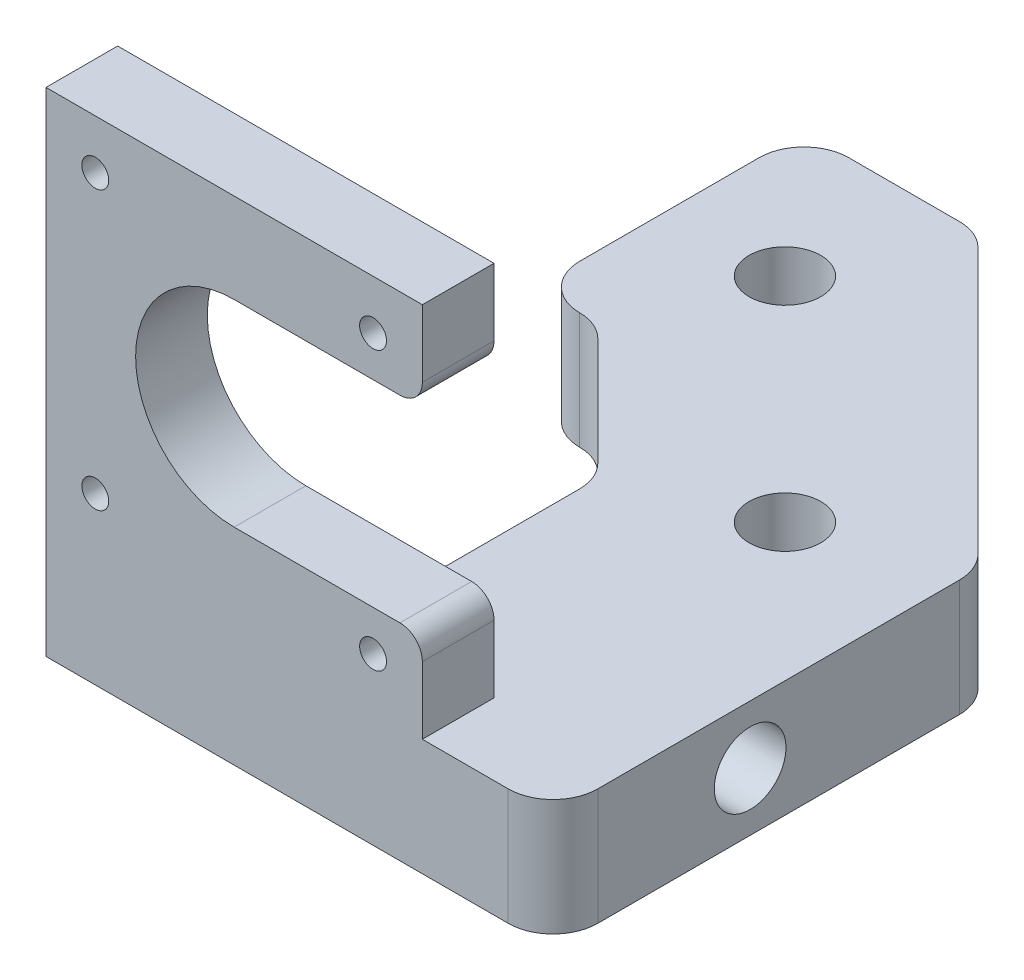
from build123d import *

# Parameters (mm, degrees)
SKETCH1_R       = 4
EXTRUDE1_DEPTH  = 13
FILLET5_R       = 5
FILLET6_R       = 5
SKETCH8_R       = 4
EXTRUDE7_DEPTH  = 30
SKETCH9_W       = 42
SKETCH9_H       = 8
EXTRUDE8_DEPTH  = 42
EXTRUDE9_REACH  = 82
SKETCH10_R      = 11
SKETCH10_R_2    = 1.5
EXTRUDE10_REACH = 10
SKETCH11_W      = 21
SKETCH11_H      = 22
FILLET7_R       = 2.5


with BuildPart() as part:
    # Sketch1 → Extrude1 (new body)
    with BuildSketch(Plane(origin=(0, 0, 0), x_dir=(1, 0, 0), z_dir=(0, 1, 0))):
        Polygon((-26.25, -50), (30.331151632, -50), (30.331151632, -2.573593129), (-2.242441497, 30), (-21.668848368, 30), (-21.668848368, 0), (-14.668848368, 0), (0.331151632, -15), (0.331151632, -42), (-26.25, -42), align=None)
        with Locations((-8.786796564, 15)):
            Circle(SKETCH1_R, mode=Mode.SUBTRACT)
        with Locations((15, -8.786796564)):
            Circle(SKETCH1_R, mode=Mode.SUBTRACT)
    extrude(amount=EXTRUDE1_DEPTH)

    # Fillet5
    fillet5_edges = [part.edges().sort_by_distance(p)[0] for p in [
        (-2.242441497, 6.5, -30),
        (30.331151632, 6.5, 2.573593129),
        (30.331151632, 6.5, 50),
        (0.331151632, 6.5, 15),
        (-14.668848368, 6.5, 0),
    ]]
    fillet(fillet5_edges, radius=FILLET5_R)

    # Fillet6
    fillet6_edges = [part.edges().sort_by_distance(p)[0] for p in [
        (-21.668848368, 6.5, 0),
        (-21.668848368, 6.5, -30),
    ]]
    fillet(fillet6_edges, radius=FILLET6_R)

    # Sketch8 → Extrude7 (cut)
    with BuildSketch(Plane.ZY.offset(-0.331151632)):
        with Locations((28, 6.5)):
            Circle(SKETCH8_R)
    extrude(amount=-EXTRUDE7_DEPTH, mode=Mode.SUBTRACT)

    # Sketch9 → Extrude8 (add)
    with BuildSketch(Plane(origin=(0, 13, 0), x_dir=(-1, 0, 0), z_dir=(0, 1, 0))):
        with Locations((5.25, 46)):
            Rectangle(SKETCH9_W, SKETCH9_H)
    extrude(amount=EXTRUDE8_DEPTH)

    # Sketch10 → Extrude9 (cut, up to next)
    with BuildSketch(Plane.XY.offset(50), mode=Mode.PRIVATE) as extrude9_sk1:
        with Locations((-5.25, 34)):
            Circle(SKETCH10_R)
    extrude9_tool1 = extrude(extrude9_sk1.sketch, amount=-EXTRUDE9_REACH, mode=Mode.PRIVATE) & part.part
    add(extrude9_tool1.solids().sort_by_distance((-5.25, 34, 50))[0], mode=Mode.SUBTRACT)
    # Sketch10 → Extrude9 (cut, up to next)
    with BuildSketch(Plane.XY.offset(50), mode=Mode.PRIVATE) as extrude9_sk2:
        with Locations((10.25, 49.5)):
            Circle(SKETCH10_R_2)
    extrude9_tool2 = extrude(extrude9_sk2.sketch, amount=-EXTRUDE9_REACH, mode=Mode.PRIVATE) & part.part
    add(extrude9_tool2.solids().sort_by_distance((10.25, 49.5, 50))[0], mode=Mode.SUBTRACT)
    # Sketch10 → Extrude9 (cut, up to next)
    with BuildSketch(Plane.XY.offset(50), mode=Mode.PRIVATE) as extrude9_sk3:
        with Locations((-20.75, 49.5)):
            Circle(SKETCH10_R_2)
    extrude9_tool3 = extrude(extrude9_sk3.sketch, amount=-EXTRUDE9_REACH, mode=Mode.PRIVATE) & part.part
    add(extrude9_tool3.solids().sort_by_distance((-20.75, 49.5, 50))[0], mode=Mode.SUBTRACT)
    # Sketch10 → Extrude9 (cut, up to next)
    with BuildSketch(Plane.XY.offset(50), mode=Mode.PRIVATE) as extrude9_sk4:
        with Locations((-20.75, 18.5)):
            Circle(SKETCH10_R_2)
    extrude9_tool4 = extrude(extrude9_sk4.sketch, amount=-EXTRUDE9_REACH, mode=Mode.PRIVATE) & part.part
    add(extrude9_tool4.solids().sort_by_distance((-20.75, 18.5, 50))[0], mode=Mode.SUBTRACT)
    # Sketch10 → Extrude9 (cut, up to next)
    with BuildSketch(Plane.XY.offset(50), mode=Mode.PRIVATE) as extrude9_sk5:
        with Locations((10.25, 18.5)):
            Circle(SKETCH10_R_2)
    extrude9_tool5 = extrude(extrude9_sk5.sketch, amount=-EXTRUDE9_REACH, mode=Mode.PRIVATE) & part.part
    add(extrude9_tool5.solids().sort_by_distance((10.25, 18.5, 50))[0], mode=Mode.SUBTRACT)

    # Sketch11 → Extrude10 (cut, up to next)
    with BuildSketch(Plane(origin=(0, 0, 42), x_dir=(-1, 0, 0), z_dir=(0, 0, -1)), mode=Mode.PRIVATE) as extrude10_sk1:
        with Locations((-5.25, 34)):
            Rectangle(SKETCH11_W, SKETCH11_H)
    extrude10_tool1 = extrude(extrude10_sk1.sketch, amount=-EXTRUDE10_REACH, mode=Mode.PRIVATE) & part.part
    add(extrude10_tool1.solids().sort_by_distance((5.25, 34, 42))[0], mode=Mode.SUBTRACT)

    # Fillet7
    fillet7_edges = [part.edges().sort_by_distance(p)[0] for p in [
        (15.75, 23, 46),
        (15.75, 45, 46),
    ]]
    fillet(fillet7_edges, radius=FILLET7_R)


solid = part.part
